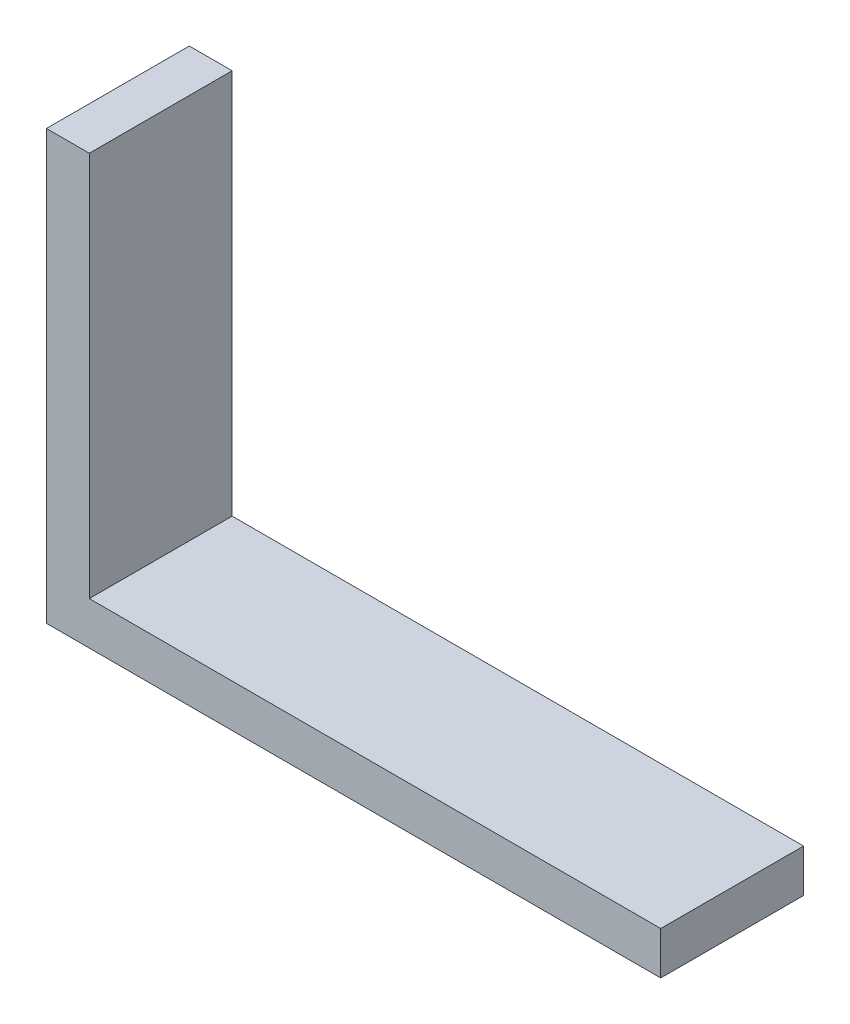
from build123d import *

# Parameters (mm, degrees)
BOSS_EXTRUDE1_DEPTH = 10


with BuildPart() as part:
    # Sketch1 → Boss-Extrude1 (new body)
    with BuildSketch(Plane.XY):
        Polygon((0, 0), (0, 30), (3, 30), (3, 3), (43, 3), (43, 0), align=None)
    extrude(amount=BOSS_EXTRUDE1_DEPTH)


solid = part.part
